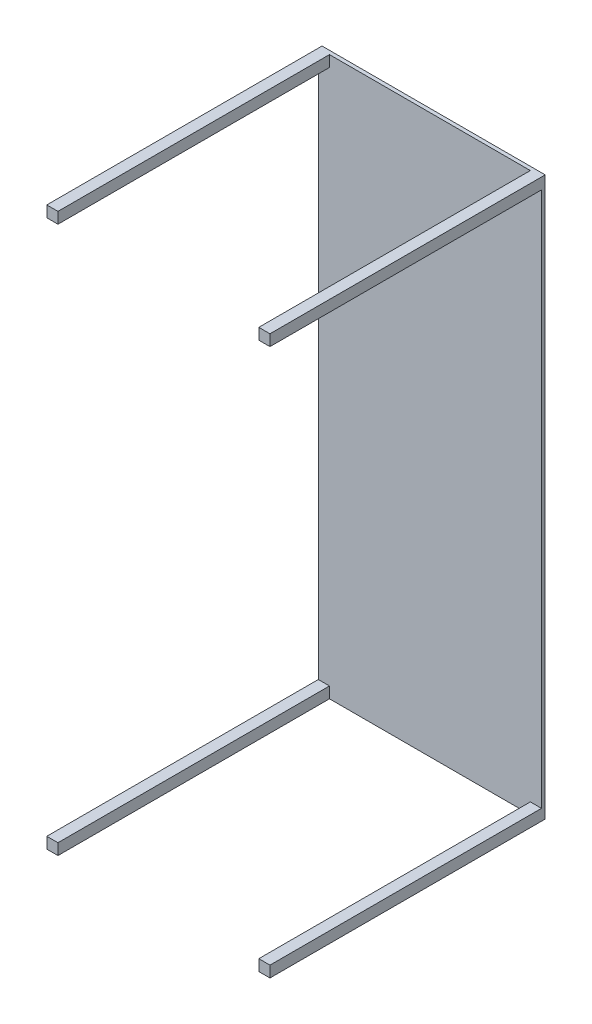
from build123d import *

# Parameters (mm, degrees)
SKETCH1_W           = 600
SKETCH1_H           = 1500
BOSS_EXTRUDE1_DEPTH = 10
SKETCH2_W           = 30
SKETCH2_H           = 30
BOSS_EXTRUDE2_DEPTH = 730


with BuildPart() as part:
    # Sketch1 → Boss-Extrude1 (new body)
    with BuildSketch(Plane.XY):
        Rectangle(SKETCH1_W, SKETCH1_H)
    extrude(amount=BOSS_EXTRUDE1_DEPTH)

    # Sketch2 → Boss-Extrude2 (add)
    with BuildSketch(Plane.XY.offset(10)):
        with Locations((-285, 735)):
            Rectangle(SKETCH2_W, SKETCH2_H)
        with Locations((285, 735)):
            Rectangle(SKETCH2_W, SKETCH2_H)
        with Locations((285, -735)):
            Rectangle(SKETCH2_W, SKETCH2_H)
        with Locations((-285, -735)):
            Rectangle(SKETCH2_W, SKETCH2_H)
    extrude(amount=BOSS_EXTRUDE2_DEPTH)


solid = part.part
